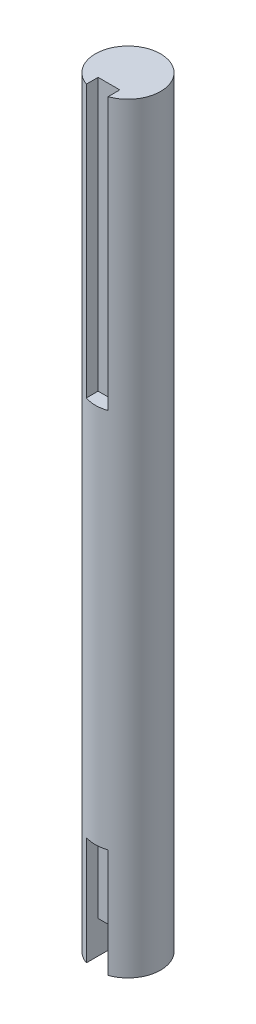
from build123d import *

# Parameters (mm, degrees)
SKETCH1_R                = 6
BOSS_EXTRUDE1_DEPTH      = 104
BOSS_EXTRUDE1_DEPTH_BACK = 36
CUT_EXTRUDE3_START       = -36
SKETCH2_W                = 4
SKETCH2_H                = 5
CUT_EXTRUDE3_DEPTH       = 20
CUT_EXTRUDE3_DEPTH_BACK  = 0.0001
CUT_EXTRUDE4_START       = 104
SKETCH2_2_W              = 4
SKETCH2_2_H              = 5
CUT_EXTRUDE4_DEPTH       = 50
CUT_EXTRUDE6_START       = -36
SKETCH3_W                = 4
SKETCH3_H                = 10
CUT_EXTRUDE6_DEPTH       = 6


with BuildPart() as part:
    # Sketch1 → Boss-Extrude1 (new body, two sides)
    with BuildSketch(Plane(origin=(0, 0, 0), x_dir=(1, 0, 0), z_dir=(0, 1, 0))) as boss_extrude1_sk:
        Circle(SKETCH1_R)
    extrude(amount=BOSS_EXTRUDE1_DEPTH)
    extrude(boss_extrude1_sk.sketch, amount=-BOSS_EXTRUDE1_DEPTH_BACK)

    # Sketch2 → Cut-Extrude3 (cut, two sides)
    with BuildSketch(Plane(origin=(0, 0, 0), x_dir=(1, 0, 0), z_dir=(0, 1, 0)).offset(CUT_EXTRUDE3_START)) as cut_extrude3_sk:
        with Locations((0, -6)):
            Rectangle(SKETCH2_W, SKETCH2_H)
    extrude(amount=CUT_EXTRUDE3_DEPTH, mode=Mode.SUBTRACT)
    extrude(cut_extrude3_sk.sketch, amount=-CUT_EXTRUDE3_DEPTH_BACK, mode=Mode.SUBTRACT)

    # Sketch2_2 → Cut-Extrude4 (cut)
    with BuildSketch(Plane(origin=(0, 0, 0), x_dir=(1, 0, 0), z_dir=(0, 1, 0)).offset(CUT_EXTRUDE4_START)):
        with Locations((0, -6)):
            Rectangle(SKETCH2_2_W, SKETCH2_2_H)
    extrude(amount=-CUT_EXTRUDE4_DEPTH, mode=Mode.SUBTRACT)

    # Sketch3 → Cut-Extrude6 (cut)
    with BuildSketch(Plane(origin=(0, 0, 0), x_dir=(1, 0, 0), z_dir=(0, 1, 0)).offset(CUT_EXTRUDE6_START)):
        with Locations((0, -6)):
            Rectangle(SKETCH3_W, SKETCH3_H)
    extrude(amount=CUT_EXTRUDE6_DEPTH, mode=Mode.SUBTRACT)


solid = part.part
